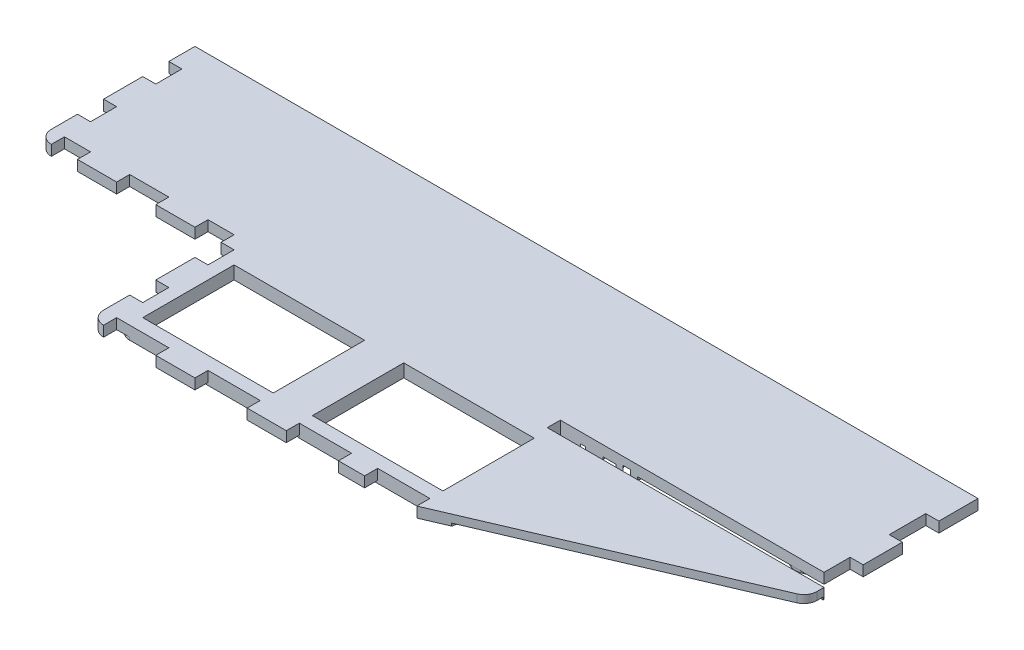
from build123d import *

# Parameters (mm, degrees)
SKETCH1_W           = 381
SKETCH1_H           = 6.35
BOSS_EXTRUDE1_DEPTH = 139.7
CUT_EXTRUDE1_DEPTH  = 7.35
SKETCH3_W           = 63.5
SKETCH3_H           = 44.45
CUT_EXTRUDE2_DEPTH  = 7.35
CUT_EXTRUDE3_DEPTH  = 1.27
CUT_EXTRUDE4_DEPTH  = 1.27
CUT_EXTRUDE5_DEPTH  = 1.27
SKETCH7_RX          = 10.638157658
SKETCH7_RY          = 7.265083279
BOSS_EXTRUDE2_DEPTH = 1.27
CUT_EXTRUDE6_DEPTH  = 2.54
SKETCH9_R           = 7.62
BOSS_EXTRUDE3_DEPTH = 1.27
SKETCH10_R          = 5.08
CUT_EXTRUDE7_DEPTH  = 2.54
CUT_EXTRUDE10_DEPTH = 1.27
SKETCH14_R          = 5.08
SKETCH14_W          = 11.43
SKETCH14_H          = 6.35
BOSS_EXTRUDE4_DEPTH = 1.27
SKETCH15_W          = 6.35
SKETCH15_H          = 12.7
CUT_EXTRUDE11_DEPTH = 6.35
SKETCH16_W          = 12.7
SKETCH16_H          = 6.35
SKETCH16_W_2        = 19.05
CUT_EXTRUDE12_DEPTH = 6.35
SKETCH17_W          = 6.35
SKETCH17_H          = 12.7
CUT_EXTRUDE13_DEPTH = 6.35
SKETCH18_W          = 25.4
SKETCH18_H          = 6.35
CUT_EXTRUDE14_DEPTH = 6.35
SKETCH19_W          = 6.35
SKETCH19_H          = 19.05
SKETCH19_H_2        = 17.78
CUT_EXTRUDE15_DEPTH = 6.35
SKETCH20_W          = 128.27
SKETCH20_H          = 6.35
CUT_EXTRUDE16_DEPTH = 6.35


with BuildPart() as part:
    # Sketch1 → Boss-Extrude1 (new body)
    with BuildSketch(Plane.XY):
        with Locations((-190.5, 3.175)):
            Rectangle(SKETCH1_W, SKETCH1_H)
    extrude(amount=BOSS_EXTRUDE1_DEPTH)

    # Sketch2 → Cut-Extrude1 (cut, through all)
    with BuildSketch(Plane.XZ):
        with BuildLine():
            ThreePointArc((-381, 69.85), (-379.140128061, 74.340128061), (-374.65, 76.2))
            Line((-374.65, 76.2), (-292.1, 76.2))
            Line((-292.1, 76.2), (-292.1, 133.35))
            ThreePointArc((-292.1, 133.35), (-290.240128061, 137.840128061), (-285.75, 139.7))
            Line((-285.75, 139.7), (-381, 139.7))
            Line((-381, 139.7), (-381, 69.85))
        make_face()
        with BuildLine():
            Line((0, 139.7), (-133.35, 139.7))
            Line((-133.35, 139.7), (-3.848612454, 84.199405337))
            ThreePointArc((-3.848612454, 84.199405337), (-1.048759064, 81.858452302), (0, 78.362834397))
            Line((0, 78.362834397), (0, 139.7))
        make_face()
    extrude(amount=-CUT_EXTRUDE1_DEPTH, mode=Mode.SUBTRACT)

    # Sketch3 → Cut-Extrude2 (cut, through all)
    with BuildSketch(Plane(origin=(0, 6.35, 0), x_dir=(1, 0, 0), z_dir=(0, 1, 0))):
        with Locations((-165.1, -104.775)):
            Rectangle(SKETCH3_W, SKETCH3_H)
        with Locations((-247.65, -104.775)):
            Rectangle(SKETCH3_W, SKETCH3_H)
    extrude(amount=-CUT_EXTRUDE2_DEPTH, mode=Mode.SUBTRACT)

    # Sketch4 → Cut-Extrude3 (cut)
    with BuildSketch(Plane.XZ):
        with BuildLine():
            Line((-3.848612454, 84.199405337), (-133.35, 139.7))
            Line((-133.35, 139.7), (-285.75, 139.7))
            ThreePointArc((-285.75, 139.7), (-290.240128061, 137.840128061), (-292.1, 133.35))
            Line((-292.1, 133.35), (-292.1, 76.2))
            Line((-292.1, 76.2), (-374.65, 76.2))
            ThreePointArc((-374.65, 76.2), (-379.140128061, 74.340128061), (-381, 69.85))
            Line((-381, 69.85), (-381, 0))
            Line((-381, 0), (0, 0))
            Line((0, 0), (0, 78.362834397))
            ThreePointArc((0, 78.362834397), (-1.048759064, 81.858452302), (-3.848612454, 84.199405337))
        make_face()
        with BuildLine():
            ThreePointArc((-285.75, 127), (-283.890128061, 131.490128061), (-279.4, 133.35))
            Line((-279.4, 133.35), (-215.9, 133.35))
            ThreePointArc((-215.9, 133.35), (-211.409871939, 131.490128061), (-209.55, 127))
            Line((-209.55, 127), (-209.55, 25.4))
            ThreePointArc((-209.55, 25.4), (-211.409871939, 20.909871939), (-215.9, 19.05))
            Line((-215.9, 19.05), (-279.4, 19.05))
            ThreePointArc((-279.4, 19.05), (-283.890128061, 20.909871939), (-285.75, 25.4))
            Line((-285.75, 25.4), (-285.75, 127))
        make_face(mode=Mode.SUBTRACT)
        with BuildLine():
            Line((-196.85, 133.35), (-127, 133.35))
            Line((-127, 133.35), (-112.137573981, 74.878893992))
            Line((-112.137573981, 74.878893992), (-125.744419224, 23.76643633))
            ThreePointArc((-125.744419224, 23.76643633), (-128.010988421, 20.365338676), (-131.88070228, 19.05))
            Line((-131.88070228, 19.05), (-196.85, 19.05))
            ThreePointArc((-196.85, 19.05), (-201.340128061, 20.909871939), (-203.2, 25.4))
            Line((-203.2, 25.4), (-203.2, 127))
            ThreePointArc((-203.2, 127), (-201.340128061, 131.490128061), (-196.85, 133.35))
        make_face(mode=Mode.SUBTRACT)
    extrude(amount=-CUT_EXTRUDE3_DEPTH, mode=Mode.SUBTRACT)

    # Sketch5 → Cut-Extrude4 (cut)
    with BuildSketch(Plane.XZ):
        with BuildLine():
            ThreePointArc((-158.992065813, 53.903274114), (-161.23709196, 53.287195771), (-163.421462968, 54.092315777))
            Line((-163.421462968, 54.092315777), (-185.887975323, 71.659056802))
            ThreePointArc((-185.887975323, 71.659056802), (-186.724879694, 74.487406876), (-184.323422249, 76.2))
            Line((-184.323422249, 76.2), (-133.639840253, 76.2))
            Line((-133.639840253, 76.2), (-133.371973018, 76.2))
            ThreePointArc((-133.371973018, 76.2), (-130.937419027, 74.384256076), (-131.983594655, 71.533029027))
            Line((-131.983594655, 71.533029027), (-158.992065813, 53.903274114))
        make_face()
        with BuildLine():
            ThreePointArc((-134.022318328, 31.104895564), (-131.650325923, 30.697594229), (-130.003252032, 32.452413293))
            Line((-130.003252032, 32.452413293), (-121.14221986, 65.737801909))
            ThreePointArc((-121.14221986, 65.737801909), (-122.107836854, 68.449087436), (-124.985111445, 68.51819835))
            Line((-124.985111445, 68.51819835), (-151.528786111, 51.191838923))
            ThreePointArc((-151.528786111, 51.191838923), (-153.252753369, 48.163841066), (-151.793048177, 44.999967667))
            Line((-151.793048177, 44.999967667), (-134.022318328, 31.104895564))
        make_face()
        with BuildLine():
            ThreePointArc((-144.407280031, 25.4), (-142.005822585, 27.112593124), (-142.842726957, 29.940943198))
            Line((-142.842726957, 29.940943198), (-159.460209971, 42.934282617))
            ThreePointArc((-159.460209971, 42.934282617), (-161.644580979, 43.739402623), (-163.889607126, 43.123324281))
            Line((-163.889607126, 43.123324281), (-183.891708315, 30.066970973))
            ThreePointArc((-183.891708315, 30.066970973), (-184.937883944, 27.215743924), (-182.503329952, 25.4))
            Line((-182.503329952, 25.4), (-144.407280031, 25.4))
        make_face()
        with BuildLine():
            Line((-196.85, 66.959325487), (-196.85, 33.882758471))
            ThreePointArc((-196.85, 33.882758471), (-195.519363254, 31.649142452), (-192.921621637, 31.755787497))
            Line((-192.921621637, 31.755787497), (-171.352886828, 45.834759471))
            ThreePointArc((-171.352886828, 45.834759471), (-169.62891957, 48.862757328), (-171.088624762, 52.026630727))
            Line((-171.088624762, 52.026630727), (-192.745446926, 68.960268685))
            ThreePointArc((-192.745446926, 68.960268685), (-195.423021831, 69.242477345), (-196.85, 66.959325487))
        make_face()
        with BuildLine():
            Line((-215.9, 34.229440484), (-215.9, 67.737366324))
            ThreePointArc((-215.9, 67.737366324), (-217.342192636, 70.027872598), (-220.031038577, 69.71731487))
            Line((-220.031038577, 69.71731487), (-239.692082997, 53.918176966))
            ThreePointArc((-239.692082997, 53.918176966), (-241.115522876, 50.944107883), (-239.685613264, 47.973143982))
            Line((-239.685613264, 47.973143982), (-220.026725421, 32.246033708))
            ThreePointArc((-220.026725421, 32.246033708), (-217.339700625, 31.940130264), (-215.9, 34.229440484))
        make_face()
        with BuildLine():
            ThreePointArc((-227.288401483, 29.923406776), (-226.478310973, 27.099242369), (-228.875126903, 25.4))
            Line((-228.875126903, 25.4), (-267.965347007, 25.4))
            ThreePointArc((-267.965347007, 25.4), (-270.361246557, 27.096634512), (-269.556385584, 29.919948547))
            Line((-269.556385584, 29.919948547), (-250.848605829, 44.953066112))
            ThreePointArc((-250.848605829, 44.953066112), (-248.466194227, 45.793141036), (-246.081959833, 44.958253456))
            Line((-246.081959833, 44.958253456), (-227.288401483, 29.923406776))
        make_face()
        with BuildLine():
            Line((-246.09497637, 56.919138608), (-227.725938458, 71.680051453))
            ThreePointArc((-227.725938458, 71.680051453), (-226.921077485, 74.503365488), (-229.316977035, 76.2))
            Line((-229.316977035, 76.2), (-267.728199395, 76.2))
            ThreePointArc((-267.728199395, 76.2), (-270.125015326, 74.500757631), (-269.314924816, 71.676593224))
            Line((-269.314924816, 71.676593224), (-250.861622366, 56.913951264))
            ThreePointArc((-250.861622366, 56.913951264), (-248.477387972, 56.079063684), (-246.09497637, 56.919138608))
        make_face()
        with BuildLine():
            Line((-279.4, 66.327898477), (-279.4, 35.455581143))
            ThreePointArc((-279.4, 35.455581143), (-277.957807364, 33.165074869), (-275.268961423, 33.475632597))
            Line((-275.268961423, 33.475632597), (-257.251499201, 47.954027754))
            ThreePointArc((-257.251499201, 47.954027754), (-255.828059322, 50.928096837), (-257.257968935, 53.899060738))
            Line((-257.257968935, 53.899060738), (-275.273274579, 68.311305253))
            ThreePointArc((-275.273274579, 68.311305253), (-277.960299375, 68.617208697), (-279.4, 66.327898477))
        make_face()
    extrude(amount=-CUT_EXTRUDE4_DEPTH, mode=Mode.SUBTRACT)

    # Sketch6 → Cut-Extrude5 (cut)
    with BuildSketch(Plane.XZ.offset(-1.27)):
        with BuildLine():
            Line((-248.158, 6.985), (-248.158, 13.335))
            ThreePointArc((-248.158, 13.335), (-251.206, 16.383), (-254.254, 13.335))
            Line((-254.254, 13.335), (-254.254, 6.985))
            ThreePointArc((-254.254, 6.985), (-251.206, 3.937), (-248.158, 6.985))
        make_face()
        with BuildLine():
            Line((-159.512, 6.985), (-159.512, 13.335))
            ThreePointArc((-159.512, 13.335), (-162.56, 16.383), (-165.608, 13.335))
            Line((-165.608, 13.335), (-165.608, 6.985))
            ThreePointArc((-165.608, 6.985), (-162.56, 3.937), (-159.512, 6.985))
        make_face()
        with BuildLine():
            Line((-140.716, 6.985), (-140.716, 13.335))
            ThreePointArc((-140.716, 13.335), (-143.764, 16.383), (-146.812, 13.335))
            Line((-146.812, 13.335), (-146.812, 6.985))
            ThreePointArc((-146.812, 6.985), (-143.764, 3.937), (-140.716, 6.985))
        make_face()
        with BuildLine():
            Line((-121.92, 6.985), (-121.92, 13.335))
            ThreePointArc((-121.92, 13.335), (-124.968, 16.383), (-128.016, 13.335))
            Line((-128.016, 13.335), (-128.016, 6.985))
            ThreePointArc((-128.016, 6.985), (-124.968, 3.937), (-121.92, 6.985))
        make_face()
        with BuildLine():
            Line((-266.954, 6.985), (-266.954, 13.335))
            ThreePointArc((-266.954, 13.335), (-270.002, 16.383), (-273.05, 13.335))
            Line((-273.05, 13.335), (-273.05, 6.985))
            ThreePointArc((-273.05, 6.985), (-270.002, 3.937), (-266.954, 6.985))
        make_face()
        with BuildLine():
            Line((-285.75, 6.985), (-285.75, 13.335))
            ThreePointArc((-285.75, 13.335), (-288.798, 16.383), (-291.846, 13.335))
            Line((-291.846, 13.335), (-291.846, 6.985))
            ThreePointArc((-291.846, 6.985), (-288.798, 3.937), (-285.75, 6.985))
        make_face()
    extrude(amount=-CUT_EXTRUDE5_DEPTH, mode=Mode.SUBTRACT)

    # Sketch7 → Boss-Extrude2 (add)
    with BuildSketch(Plane.XZ.offset(-1.27)):
        with Locations(Location((-102.329210388, 61.253935302), (0, 0, 90))):
            Ellipse(SKETCH7_RX, SKETCH7_RY)
    extrude(amount=BOSS_EXTRUDE2_DEPTH)

    # Sketch8 → Cut-Extrude6 (cut)
    with BuildSketch(Plane.XZ):
        with BuildLine():
            add(Edge.make_bspline(
                [(-102.329210388, 53.155777643), (-102.112758869, 53.155777643), (-101.90165855, 53.184733869), (-101.488693819, 53.29262333), (-101.285989099, 53.372491654), (-100.906134378, 53.565827315), (-100.726271614, 53.679807762), (-100.382645705, 53.935462419), (-100.219893263, 54.076719563), (-99.764069992, 54.523015248), (-99.497769004, 54.853884591), (-99.020239481, 55.564478945), (-98.814571853, 55.936822891), (-98.456537688, 56.702496854), (-98.303821873, 57.096880827), (-98.043897216, 57.905627606), (-97.93694989, 58.320684281), (-97.685170772, 59.564921728), (-97.604474239, 60.402865358), (-97.603955181, 61.671468822), (-97.624537227, 62.098727862), (-97.707574037, 62.943449926), (-97.769697493, 63.360708886), (-98.019835892, 64.596695994), (-98.268534926, 65.400397992), (-98.81064993, 66.564087993), (-99.016899152, 66.93745653), (-99.490891269, 67.644695452), (-99.76140618, 67.981745124), (-100.216477408, 68.428053725), (-100.376714264, 68.567454964), (-100.718552192, 68.82283879), (-100.901455485, 68.939296763), (-101.281621707, 69.133512578), (-101.480360605, 69.212535587), (-101.897705612, 69.322623081), (-102.108175779, 69.351318098), (-102.532927978, 69.352836862), (-102.749721759, 69.324409496), (-103.163652722, 69.217383132), (-103.364910451, 69.138724573), (-103.747979792, 68.944703036), (-103.92786111, 68.8308471), (-104.269743776, 68.577289353), (-104.432452105, 68.436717912), (-104.892344941, 67.987565013), (-105.158068026, 67.657051526), (-105.632472982, 66.952651746), (-105.84141111, 66.575855339), (-106.381043429, 65.423036607), (-106.633833171, 64.616915287), (-106.88839125, 63.363953584), (-106.950841871, 62.942910835), (-107.033547657, 62.102731031), (-107.054050785, 61.682251454), (-107.054532282, 60.840534907), (-107.034513011, 60.419297982), (-106.952348017, 59.576036803), (-106.889682762, 59.152120735), (-106.637395321, 57.904861607), (-106.38643813, 57.098809521), (-105.845816734, 55.940225585), (-105.638318792, 55.565088352), (-105.283208535, 55.036057222), (-105.157215657, 54.864800233), (-104.887261102, 54.534276909), (-104.742776803, 54.374616224), (-104.438331426, 54.076520809), (-104.277847031, 53.937256286), (-103.936531746, 53.682820747), (-103.753864897, 53.566720171), (-103.373085917, 53.372735724), (-103.175006788, 53.294335437), (-102.759198786, 53.185043833), (-102.545661908, 53.155777643), (-102.329210388, 53.155777643)],
                knots=[0, 0, 0, 0, 0.015625, 0.015625, 0.03125, 0.03125, 0.046875, 0.046875, 0.0625, 0.0625, 0.09375, 0.09375, 0.125, 0.125, 0.15625, 0.15625, 0.1875, 0.1875, 0.25, 0.25, 0.28125, 0.28125, 0.3125, 0.3125, 0.375, 0.375, 0.40625, 0.40625, 0.4375, 0.4375, 0.453125, 0.453125, 0.46875, 0.46875, 0.484375, 0.484375, 0.5, 0.5, 0.515625, 0.515625, 0.53125, 0.53125, 0.546875, 0.546875, 0.5625, 0.5625, 0.59375, 0.59375, 0.625, 0.625, 0.6875, 0.6875, 0.71875, 0.71875, 0.75, 0.75, 0.78125, 0.78125, 0.8125, 0.8125, 0.875, 0.875, 0.90625, 0.90625, 0.921875, 0.921875, 0.9375, 0.9375, 0.953125, 0.953125, 0.96875, 0.96875, 0.984375, 0.984375, 1, 1, 1, 1], degree=3))
        make_face()
    extrude(amount=-CUT_EXTRUDE6_DEPTH, mode=Mode.SUBTRACT)

    # Sketch9 → Boss-Extrude3 (add)
    with BuildSketch(Plane.XZ.offset(-1.27)):
        with Locations((-20.387686115, 60.831492086)):
            Circle(SKETCH9_R)
    extrude(amount=BOSS_EXTRUDE3_DEPTH)

    # Sketch10 → Cut-Extrude7 (cut)
    with BuildSketch(Plane.XZ):
        with Locations((-20.387686115, 60.831492086)):
            Circle(SKETCH10_R)
    extrude(amount=-CUT_EXTRUDE7_DEPTH, mode=Mode.SUBTRACT)

    # Sketch13 → Cut-Extrude10 (cut)
    with BuildSketch(Plane.XZ.offset(-1.27)):
        with BuildLine():
            Line((0, 75.388570939), (0, 78.362834397))
            ThreePointArc((0, 78.362834397), (-1.048759064, 81.858452302), (-3.848612454, 84.199405337))
            Line((-3.848612454, 84.199405337), (-121.475018203, 134.610722087))
            Line((-121.475018203, 134.610722087), (-119.147762172, 125.454933261))
            Line((-119.147762172, 125.454933261), (-106.421688444, 75.388570939))
            Line((-106.421688444, 75.388570939), (0, 75.388570939))
        make_face()
    extrude(amount=-CUT_EXTRUDE10_DEPTH, mode=Mode.SUBTRACT)

    # Sketch14 → Boss-Extrude4 (add)
    with BuildSketch(Plane.XZ.offset(-1.27)):
        with Locations((-370.84, 62.855298511)):
            Circle(SKETCH14_R)
        with Locations((-349.885, 69.692429512)):
            Rectangle(SKETCH14_W, SKETCH14_H)
    extrude(amount=BOSS_EXTRUDE4_DEPTH)

    # Sketch15 → Cut-Extrude11 (cut)
    with BuildSketch(Plane.XZ.offset(-1.27)):
        with Locations((-377.825, 50.8)):
            Rectangle(SKETCH15_W, SKETCH15_H)
        with Locations((-377.825, 19.05)):
            Rectangle(SKETCH15_W, SKETCH15_H)
    extrude(amount=-CUT_EXTRUDE11_DEPTH, mode=Mode.SUBTRACT)

    # Sketch16 → Cut-Extrude12 (cut)
    with BuildSketch(Plane.XZ.offset(-1.27)):
        with Locations((-368.3, 73.025)):
            Rectangle(SKETCH16_W, SKETCH16_H)
        with Locations((-333.375, 73.025)):
            Rectangle(SKETCH16_W_2, SKETCH16_H)
        with Locations((-298.45, 73.025)):
            Rectangle(SKETCH16_W, SKETCH16_H)
    extrude(amount=-CUT_EXTRUDE12_DEPTH, mode=Mode.SUBTRACT)

    # Sketch17 → Cut-Extrude13 (cut)
    with BuildSketch(Plane.XZ.offset(-1.27)):
        with Locations((-288.925, 82.55)):
            Rectangle(SKETCH17_W, SKETCH17_H)
        with Locations((-288.925, 114.3)):
            Rectangle(SKETCH17_W, SKETCH17_H)
    extrude(amount=-CUT_EXTRUDE13_DEPTH, mode=Mode.SUBTRACT)

    # Sketch18 → Cut-Extrude14 (cut)
    with BuildSketch(Plane.XZ.offset(-1.27)):
        with Locations((-273.05, 136.525)):
            Rectangle(SKETCH18_W, SKETCH18_H)
        with Locations((-228.6, 136.525)):
            Rectangle(SKETCH18_W, SKETCH18_H)
        with Locations((-184.15, 136.525)):
            Rectangle(SKETCH18_W, SKETCH18_H)
        with Locations((-146.05, 136.525)):
            Rectangle(SKETCH18_W, SKETCH18_H)
    extrude(amount=-CUT_EXTRUDE14_DEPTH, mode=Mode.SUBTRACT)

    # Sketch19 → Cut-Extrude15 (cut)
    with BuildSketch(Plane.XZ.offset(-1.27)):
        with Locations((-3.175, 65.405)):
            Rectangle(SKETCH19_W, SKETCH19_H)
        with Locations((-3.175, 27.94)):
            Rectangle(SKETCH19_W, SKETCH19_H_2)
    extrude(amount=-CUT_EXTRUDE15_DEPTH, mode=Mode.SUBTRACT)

    # Sketch20 → Cut-Extrude16 (cut)
    with BuildSketch(Plane(origin=(0, 6.35, 0), x_dir=(1, 0, 0), z_dir=(0, 1, 0))):
        with Locations((-70.485, -71.755)):
            Rectangle(SKETCH20_W, SKETCH20_H)
    extrude(amount=-CUT_EXTRUDE16_DEPTH, mode=Mode.SUBTRACT)


solid = part.part
